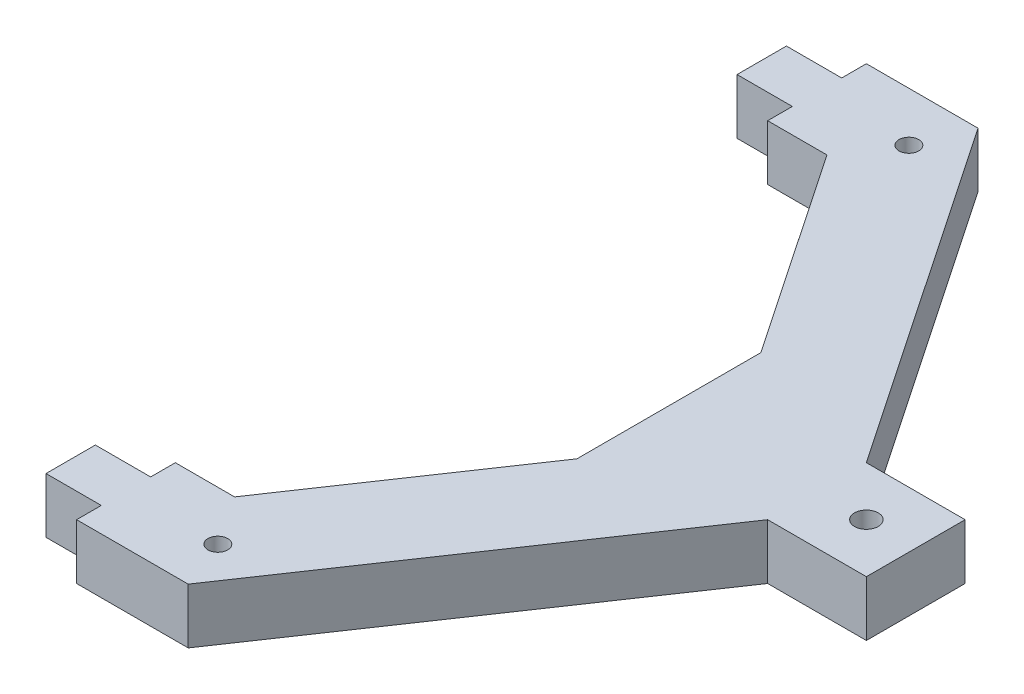
from build123d import *

# Parameters (mm, degrees)
BOSS_EXTRUDE1_DEPTH = 14
SKETCH2_W           = 14
SKETCH2_H           = 12.5
BOSS_EXTRUDE2_DEPTH = 14
HOLE1_D             = 5


with BuildPart() as part:
    # Sketch1 → Boss-Extrude1 (new body)
    with BuildSketch(Plane(origin=(0, 0, 0), x_dir=(1, 0, 0), z_dir=(0, 1, 0))):
        with BuildLine():
            Line((-37.5, 12.5), (9.5, 12.5))
            ThreePointArc((9.5, 12.5), (12.5, 15.5), (15.5, 12.5))
            Line((15.5, 12.5), (25, 12.5))
            Line((25, 12.5), (25, 25))
            Line((25, 25), (0, 25))
            Line((0, 25), (-59.234271291, 112.5))
            Line((-59.234271291, 112.5), (-87.5, 112.5))
            Line((-87.5, 112.5), (-87.5, 87.5))
            Line((-87.5, 87.5), (-72.5, 87.5))
            Line((-72.5, 87.5), (-37.5, 35.798511432))
            Line((-37.5, 35.798511432), (-37.5, 12.5))
        make_face()
    extrude(amount=BOSS_EXTRUDE1_DEPTH)

    # Sketch2 → Boss-Extrude2 (add)
    with BuildSketch(Plane(origin=(0, 14, 0), x_dir=(1, 0, 0), z_dir=(0, 1, 0))):
        with Locations((-94.5, 100)):
            Rectangle(SKETCH2_W, SKETCH2_H)
    extrude(amount=-BOSS_EXTRUDE2_DEPTH)

    # Mirror1: part across plane


with BuildPart() as part_1:
    add(part.part)
    add(part.part.mirror(Plane(origin=(0, 14, -12.5), x_dir=(1, 0, 0), z_dir=(0, 0, -1))))

    # Hole1 (through all)
    with Locations(Plane(origin=(0, 14, 0), x_dir=(1, 0, 0), z_dir=(0, 1, 0))):
        with Locations((-64.234271291, 100), (-64.234271291, -75)):
            Hole(HOLE1_D / 2)


solid = part_1.part
